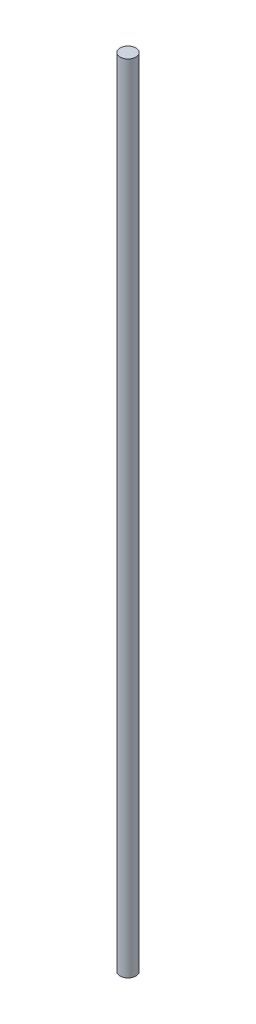
from build123d import *

# Parameters (mm, degrees)
SKETCH1_R           = 2.5
BOSS_EXTRUDE1_DEPTH = 250


with BuildPart() as part:
    # Sketch1 → Boss-Extrude1 (new body)
    with BuildSketch(Plane(origin=(0, 0, 0), x_dir=(1, 0, 0), z_dir=(0, 1, 0))):
        Circle(SKETCH1_R)
    extrude(amount=BOSS_EXTRUDE1_DEPTH)


solid = part.part
